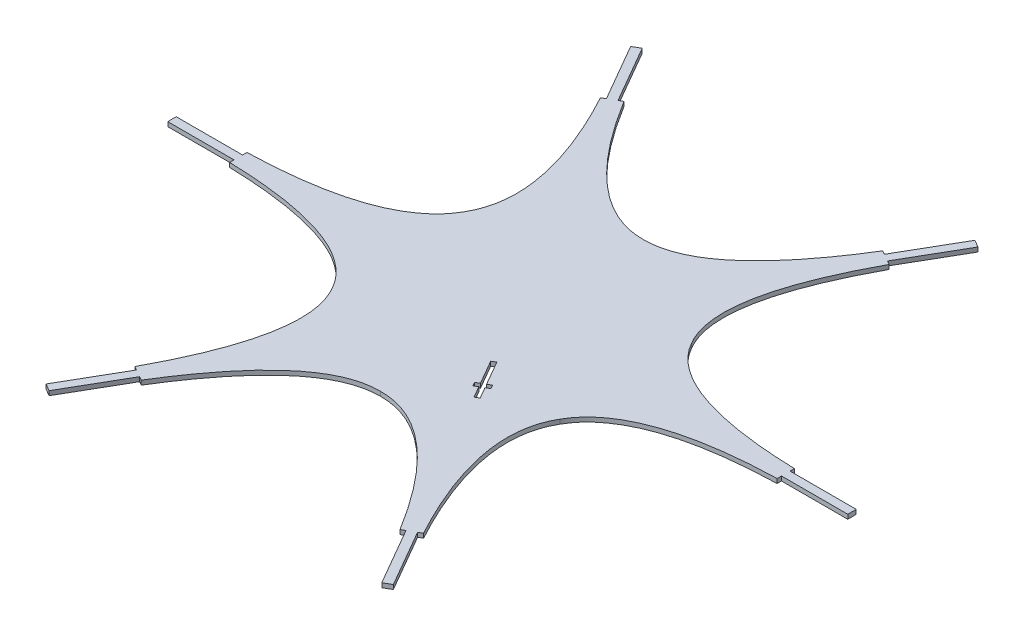
from build123d import *

# Parameters (mm, degrees)
BOSS_EXTRUDE1_DEPTH = 4


with BuildPart() as part:
    # Sketch1 → Boss-Extrude1 (new body)
    with BuildSketch(Plane(origin=(0, -95.648578892, 0), x_dir=(-1, 0, 0), z_dir=(0, -1, 0))):
        with BuildLine():
            Line((-123.018568843, 257.712687792), (-116.306871964, 261.587687792))
            Line((-116.306871964, 261.587687792), (-86.056888913, 209.19318022))
            Line((-86.056888913, 209.19318022), (-82.592787298, 211.19318022))
            add(Edge.make_bspline(
                [(-82.592787298, 211.19318022), (-20.425563037, 110.136816529), (35.572246121, 110.775338662)],
                knots=[0, 0, 0, 1, 1, 1], degree=2))
            add(Edge.make_bspline(
                [(153.737279537, 211.193180221), (91.570055279, 110.136816529), (35.572246121, 110.775338662)],
                knots=[0, 0, 0, 1, 1, 1], degree=2))
            Line((153.737279537, 211.193180221), (157.201381153, 209.193180221))
            Line((157.201381153, 209.193180221), (187.451364204, 261.587687793))
            Line((187.451364204, 261.587687793), (194.163061083, 257.712687793))
            Line((194.163061083, 257.712687793), (163.913078032, 205.318180221))
            Line((163.913078032, 205.318180221), (167.377179647, 203.318180221))
            add(Edge.make_bspline(
                [(167.377179647, 203.318180221), (110.943413608, 98.951602883), (139.495294576, 50.775338663)],
                knots=[0, 0, 0, 1, 1, 1], degree=2))
            add(Edge.make_bspline(
                [(285.542213066, -1.349661336), (166.941222766, 1.960552309), (139.495294576, 50.775338663)],
                knots=[0, 0, 0, 1, 1, 1], degree=2))
            Line((285.542213066, -1.349661336), (285.542213066, -5.349661336))
            Line((285.542213066, -5.349661336), (346.042179168, -5.349661336))
            Line((346.042179168, -5.349661336), (346.042179168, -13.099661336))
            Line((346.042179168, -13.099661336), (285.542213066, -13.099661336))
            Line((285.542213066, -13.099661336), (285.542213066, -17.099661336))
            add(Edge.make_bspline(
                [(285.542213066, -17.099661336), (166.941222766, -20.409874983), (139.495294576, -69.224661337)],
                knots=[0, 0, 0, 1, 1, 1], degree=2))
            add(Edge.make_bspline(
                [(167.377179649, -221.767502894), (110.943413609, -117.400925558), (139.495294576, -69.224661337)],
                knots=[0, 0, 0, 1, 1, 1], degree=2))
            Line((167.377179649, -221.767502894), (163.913078034, -223.767502894))
            Line((163.913078034, -223.767502894), (194.163061085, -276.162010466))
            Line((194.163061085, -276.162010466), (187.451364206, -280.037010466))
            Line((187.451364206, -280.037010466), (157.201381155, -227.642502894))
            Line((157.201381155, -227.642502894), (153.737279539, -229.642502894))
            add(Edge.make_bspline(
                [(153.737279539, -229.642502894), (91.57005528, -128.586139204), (35.572246122, -129.224661338)],
                knots=[0, 0, 0, 1, 1, 1], degree=2))
            add(Edge.make_bspline(
                [(-82.592787296, -229.642502896), (-20.425563036, -128.586139204), (35.572246122, -129.224661338)],
                knots=[0, 0, 0, 1, 1, 1], degree=2))
            Line((-82.592787296, -229.642502896), (-86.056888911, -227.642502895))
            Line((-86.056888911, -227.642502895), (-116.306871962, -280.037010467))
            Line((-116.306871962, -280.037010467), (-123.018568841, -276.162010467))
            Line((-123.018568841, -276.162010467), (-92.76858579, -223.767502895))
            Line((-92.76858579, -223.767502895), (-96.232687406, -221.767502895))
            add(Edge.make_bspline(
                [(-96.232687406, -221.767502895), (-39.798921364, -117.400925558), (-68.350802332, -69.224661338)],
                knots=[0, 0, 0, 1, 1, 1], degree=2))
            add(Edge.make_bspline(
                [(-214.397720824, -17.099661339), (-95.796730523, -20.409874984), (-68.350802332, -69.224661338)],
                knots=[0, 0, 0, 1, 1, 1], degree=2))
            Line((-214.397720824, -17.099661339), (-214.397720824, -13.099661338))
            Line((-214.397720824, -13.099661338), (-274.897686926, -13.099661338))
            Line((-274.897686926, -13.099661338), (-274.897686926, -5.349661338))
            Line((-274.897686926, -5.349661338), (-214.397720824, -5.349661338))
            Line((-214.397720824, -5.349661338), (-214.397720824, -1.349661338))
            add(Edge.make_bspline(
                [(-214.397720824, -1.349661338), (-95.796730523, 1.960552308), (-68.350802333, 50.775338662)],
                knots=[0, 0, 0, 1, 1, 1], degree=2))
            add(Edge.make_bspline(
                [(-96.232687408, 203.31818022), (-39.798921365, 98.951602882), (-68.350802333, 50.775338662)],
                knots=[0, 0, 0, 1, 1, 1], degree=2))
            Line((-96.232687408, 203.31818022), (-92.768585792, 205.31818022))
            Line((-92.768585792, 205.31818022), (-123.018568843, 257.712687792))
        make_face()
        Polygon((9.149169363, -55.090772776), (-3.656970853, -77.271658278), (-0.192869237, -79.271658278), (-2.192869237, -82.735759893), (-5.656970853, -80.735759893), (-11.656970853, -91.128064739), (-15.207675008, -89.078064739), (-9.207675008, -78.685759893), (-12.671776623, -76.685759893), (-10.671776623, -73.221658278), (-7.207675008, -75.221658278), (5.598465207, -53.040772776), align=None, mode=Mode.SUBTRACT)
    extrude(amount=BOSS_EXTRUDE1_DEPTH)


solid = part.part
